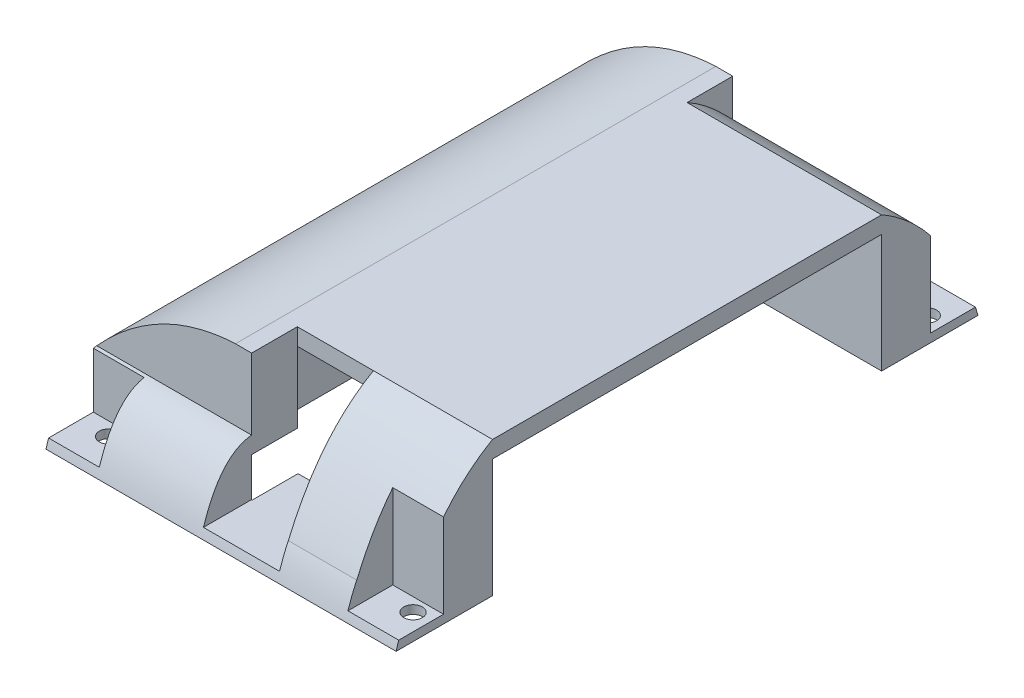
from build123d import *

# Parameters (mm, degrees)
SKETCH1_W           = 23.368
SKETCH1_H           = 72.136
BOSS_EXTRUDE1_DEPTH = 2.54
SKETCH2_W           = 2.54
SKETCH2_H           = 58.42
CUT_EXTRUDE1_DEPTH  = 2.54
SKETCH3_W           = 2.54
SKETCH3_H           = 6.858
BOSS_EXTRUDE2_DEPTH = 8.128
SKETCH4_W           = 31.75
SKETCH4_H           = 58.42
BOSS_EXTRUDE3_DEPTH = 2.54
SKETCH5_W           = 2.54
SKETCH5_H           = 6.858
BOSS_EXTRUDE4_DEPTH = 2.54
BOSS_EXTRUDE5_START = -11.684
BOSS_EXTRUDE5_DEPTH = 52.578
BOSS_EXTRUDE6_DEPTH = 29.21
SKETCH10_W          = 7.62
SKETCH10_H          = 7.112
CUT_EXTRUDE2_DEPTH  = 31.242
SKETCH12_R          = 1.397
CUT_EXTRUDE3_DEPTH  = 21.3200001
BOSS_EXTRUDE7_DEPTH = 72.136
SKETCH14_W          = 8.128
SKETCH14_H          = 7.62
SKETCH14_W_2        = 11.43
SKETCH14_H_2        = 14.478
CUT_EXTRUDE4_DEPTH  = 31.242


with BuildPart() as part:
    # Sketch1 → Boss-Extrude1 (new body)
    with BuildSketch(Plane(origin=(0, 0, 0), x_dir=(1, 0, 0), z_dir=(0, 1, 0))):
        Rectangle(SKETCH1_W, SKETCH1_H)
    extrude(amount=BOSS_EXTRUDE1_DEPTH)

    # Sketch2 → Cut-Extrude1 (cut)
    with BuildSketch(Plane(origin=(0, 2.54, 0), x_dir=(1, 0, 0), z_dir=(0, 1, 0))):
        with Locations((10.414, 0)):
            Rectangle(SKETCH2_W, SKETCH2_H)
    extrude(amount=-CUT_EXTRUDE1_DEPTH, mode=Mode.SUBTRACT)

    # Sketch3 → Boss-Extrude2 (add)
    with BuildSketch(Plane(origin=(0, 2.54, 0), x_dir=(1, 0, 0), z_dir=(0, 1, 0))):
        with Locations((10.414, -32.639)):
            Rectangle(SKETCH3_W, SKETCH3_H)
        with Locations((10.414, 32.639)):
            Rectangle(SKETCH3_W, SKETCH3_H)
    extrude(amount=BOSS_EXTRUDE2_DEPTH)



with BuildPart() as body_2:
    # Sketch4 → Boss-Extrude3 (new body)
    with BuildSketch(Plane(origin=(0, 10.668, 0), x_dir=(1, 0, 0), z_dir=(0, 1, 0))):
        with Locations((25.019, 0)):
            Rectangle(SKETCH4_W, SKETCH4_H)
    extrude(amount=BOSS_EXTRUDE3_DEPTH)


with BuildPart() as part_1:
    add(part.part)

    add(body_2.part)  # Boss-Extrude4 merges body 2
    # Sketch5 → Boss-Extrude4 (add)
    with BuildSketch(Plane(origin=(0, 10.668, 0), x_dir=(1, 0, 0), z_dir=(0, 1, 0))):
        with Locations((10.414, -32.639)):
            Rectangle(SKETCH5_W, SKETCH5_H)
        with Locations((10.414, 32.639)):
            Rectangle(SKETCH5_W, SKETCH5_H)
    extrude(amount=BOSS_EXTRUDE4_DEPTH)

    # Sketch6 → Boss-Extrude5 (add)
    with BuildSketch(Plane(origin=(0, 0, 0), x_dir=(0, 0, -1), z_dir=(1, 0, 0)).offset(BOSS_EXTRUDE5_START)):
        with BuildLine():
            add(Edge.make_bspline(
                [(43.688, -7.112), (41.104515695, 2.079413445), (36.068, 2.54)],
                knots=[0, 0, 0, 0.627076912, 0.627076912, 0.627076912], degree=2))
            Line((36.068, 2.54), (36.068, -7.112))
            Line((36.068, -7.112), (43.688, -7.112))
        make_face()
    boss_extrude5 = extrude(amount=BOSS_EXTRUDE5_DEPTH)

    # Sketch7 → Boss-Extrude6 (add)
    with BuildSketch(Plane(origin=(11.684, 0, 0), x_dir=(0, 0, -1), z_dir=(1, 0, 0))):
        with BuildLine():
            add(Edge.make_bspline(
                [(36.068, 7.434839088), (33.013673055, 11.048422605), (29.21, 13.208)],
                knots=[0.279115305, 0.279115305, 0.279115305, 0.460674554, 0.460674554, 0.460674554], degree=2))
            Line((29.21, 13.208), (29.21, 10.668))
            Line((29.21, 10.668), (29.21, 0))
            Line((29.21, 0), (36.068, 0))
            Line((36.068, 0), (36.068, 2.54))
            Line((36.068, 2.54), (36.068, 7.434839088))
        make_face()
        with BuildLine():
            add(Edge.make_bspline(
                [(43.688, -7.112), (40.763488669, 1.879592133), (36.068, 7.434839088)],
                knots=[0, 0, 0, 0.279115305, 0.279115305, 0.279115305], degree=2))
            Line((36.068, 7.434839088), (36.068, 2.54))
            Line((36.068, 2.54), (36.068, 0))
            Line((36.068, 0), (29.21, 0))
            Line((29.21, 0), (29.21, -7.112))
            Line((29.21, -7.112), (43.688, -7.112))
        make_face()
    boss_extrude6 = extrude(amount=BOSS_EXTRUDE6_DEPTH)

    # Sketch10 → Cut-Extrude2 (cut)
    with BuildSketch(Plane(origin=(0, 25.4, 0), x_dir=(1, 0, 0), z_dir=(0, 1, 0))):
        with Locations((-7.874, 40.132)):
            Rectangle(SKETCH10_W, SKETCH10_H)
        with Locations((37.084, 40.132)):
            Rectangle(SKETCH10_W, SKETCH10_H)
    cut_extrude2 = extrude(amount=-CUT_EXTRUDE2_DEPTH, mode=Mode.SUBTRACT)

    # Sketch12 → Cut-Extrude3 (cut, through all)
    with BuildSketch(Plane.XZ.offset(7.112)):
        with Locations((-7.366, -38.608)):
            Circle(SKETCH12_R)
        with Locations((38.354, -38.608)):
            Circle(SKETCH12_R)
    cut_extrude3 = extrude(amount=-CUT_EXTRUDE3_DEPTH, mode=Mode.SUBTRACT)

    # Mirror1: Boss-Extrude5, Boss-Extrude6, Cut-Extrude2, Cut-Extrude3 across plane
    add(boss_extrude5.mirror(Plane.XY))
    add(boss_extrude6.mirror(Plane.XY))
    add(cut_extrude2.mirror(Plane.XY), mode=Mode.SUBTRACT)
    add(cut_extrude3.mirror(Plane.XY), mode=Mode.SUBTRACT)

    # Sketch13 → Boss-Extrude7 (add)
    with BuildSketch(Plane.XY.offset(36.068)):
        with BuildLine():
            Line((9.144, 2.54), (9.144, 13.208))
            add(Edge.make_bspline(
                [(-11.684, 2.54), (-2.430581771, 12.68572622), (9.144, 13.208)],
                knots=[0, 0, 0, 0.902085906, 0.902085906, 0.902085906], degree=2))
            Line((-11.684, 2.54), (9.144, 2.54))
        make_face()
    extrude(amount=-BOSS_EXTRUDE7_DEPTH)

    # Sketch14 → Cut-Extrude4 (cut)
    with BuildSketch(Plane(origin=(0, 25.4, 0), x_dir=(1, 0, 0), z_dir=(0, 1, 0))):
        with Locations((5.08, 39.878)):
            Rectangle(SKETCH14_W, SKETCH14_H)
        with Locations((17.289418024, -36.449)):
            Rectangle(SKETCH14_W_2, SKETCH14_H_2)
    extrude(amount=-CUT_EXTRUDE4_DEPTH, mode=Mode.SUBTRACT)


solid = part_1.part
